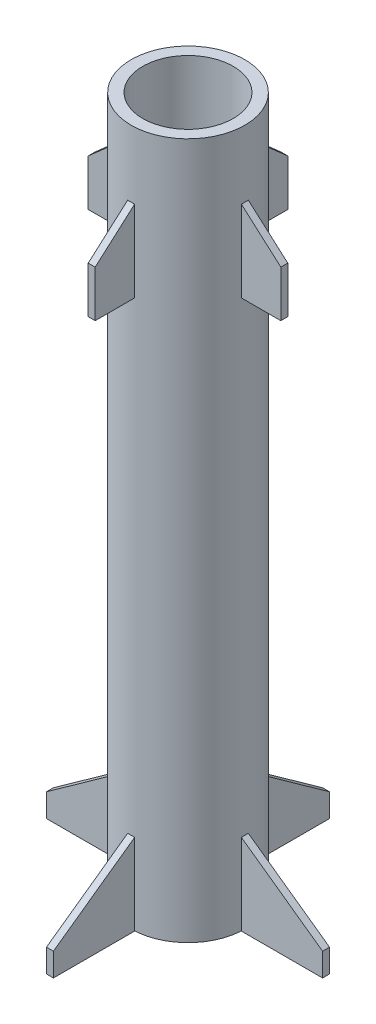
from build123d import *

# Parameters (mm, degrees)
ESBO_O1_R                = 24.5
ESBO_O1_R_2              = 19.5
RESSALTO_EXTRUS_O1_DEPTH = 300
RESSALTO_EXTRUS_O2_DEPTH = 1.5
RESSALTO_EXTRUS_O3_DEPTH = 1.5
PADR_OCIRCULAR17_COUNT   = 4
PADR_OCIRCULAR18_COUNT   = 4


with BuildPart() as part:
    # Esboço1 → Ressalto-extrusão1 (new body)
    with BuildSketch(Plane(origin=(0, 0, 0), x_dir=(1, 0, 0), z_dir=(0, 1, 0))):
        Circle(ESBO_O1_R)
        Circle(ESBO_O1_R_2, mode=Mode.SUBTRACT)
    extrude(amount=RESSALTO_EXTRUS_O1_DEPTH)


with BuildPart() as body_2:
    # Esboço2 → Ressalto-extrusão2 (new, symmetric)
    with BuildSketch(Plane.XY):
        Polygon((24.5, 271.302948914), (24.5, 236.302948914), (41.5, 236.302948914), (41.5, 256.302948914), align=None)
    extrude(amount=RESSALTO_EXTRUS_O2_DEPTH, both=True)

    # Esboço2<3> → Ressalto-extrusão3 (add, symmetric)
    with BuildSketch(Plane.XY):
        Polygon((24.5, 0), (59.5, 0), (59.5, 10), (24.5, 35), align=None)
        Polygon((24.5, 271.302948914), (24.5, 236.302948914), (41.5, 236.302948914), (41.5, 256.302948914), align=None)
    extrude(amount=RESSALTO_EXTRUS_O3_DEPTH, both=True)


with BuildPart() as ressalto_extrus_o3_piece_1:
    # of the separate pieces the step leaves, piece 1, a body of its own (ressalto_extrus_o3_pieces)
    add(body_2.part.solids().sort_by_distance((24.5, 0, -1.5))[0])


with BuildPart() as ressalto_extrus_o3_piece_2:
    # of the separate pieces the step leaves, piece 2, a body of its own (ressalto_extrus_o3_pieces)
    add(body_2.part.solids().sort_by_distance((24.5, 271.302948914, -1.5))[0])


with BuildPart() as padr_ocircular17_1:
    # PadrãoCircular17: pattern copy
    add(ressalto_extrus_o3_piece_2.part.rotate(Axis((0, 300, 0), (0, -1, 0)), 1 * 360 / PADR_OCIRCULAR17_COUNT))


with BuildPart() as padr_ocircular17_2:
    # PadrãoCircular17: pattern copy
    add(ressalto_extrus_o3_piece_2.part.rotate(Axis((0, 300, 0), (0, -1, 0)), 2 * 360 / PADR_OCIRCULAR17_COUNT))


with BuildPart() as padr_ocircular17_3:
    # PadrãoCircular17: pattern copy
    add(ressalto_extrus_o3_piece_2.part.rotate(Axis((0, 300, 0), (0, -1, 0)), 3 * 360 / PADR_OCIRCULAR17_COUNT))


with BuildPart() as padr_ocircular18_1:
    # PadrãoCircular18: pattern copy
    add(ressalto_extrus_o3_piece_1.part.rotate(Axis((0, 300, 0), (0, -1, 0)), 1 * 360 / PADR_OCIRCULAR18_COUNT))


with BuildPart() as padr_ocircular18_2:
    # PadrãoCircular18: pattern copy
    add(ressalto_extrus_o3_piece_1.part.rotate(Axis((0, 300, 0), (0, -1, 0)), 2 * 360 / PADR_OCIRCULAR18_COUNT))


with BuildPart() as padr_ocircular18_3:
    # PadrãoCircular18: pattern copy
    add(ressalto_extrus_o3_piece_1.part.rotate(Axis((0, 300, 0), (0, -1, 0)), 3 * 360 / PADR_OCIRCULAR18_COUNT))


solid = Compound([part.part, ressalto_extrus_o3_piece_1.part, ressalto_extrus_o3_piece_2.part, padr_ocircular17_1.part, padr_ocircular17_2.part, padr_ocircular17_3.part, padr_ocircular18_1.part, padr_ocircular18_2.part, padr_ocircular18_3.part])
